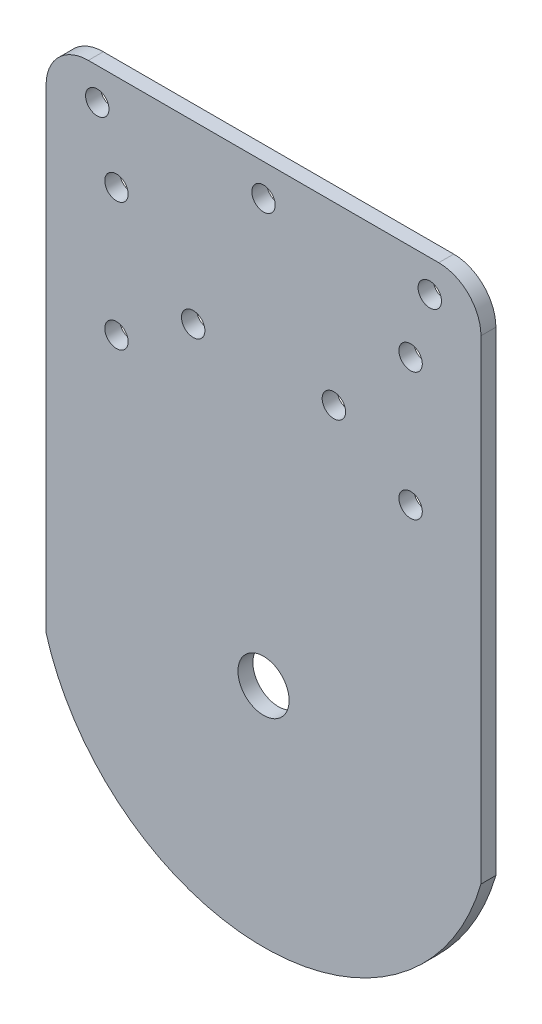
from build123d import *

# Parameters (mm, degrees)
SKETCH1_R             = 4
BOSS_EXTRUDE1_DEPTH   = 2.3368
F_6_CLEARANCE_HOLE1_D = 3.6576
FILLET1_R             = 6.6


with BuildPart() as part:
    # Sketch1 → Boss-Extrude1 (new body)
    with BuildSketch(Plane.XY):
        with BuildLine():
            Line((34, 71), (-34, 71))
            Line((-34, 71), (-34, -9.856977224))
            ThreePointArc((-34, -9.856977224), (0, -35.4), (34, -9.856977224))
            Line((34, -9.856977224), (34, 71))
        make_face()
        Circle(SKETCH1_R, mode=Mode.SUBTRACT)
    extrude(amount=BOSS_EXTRUDE1_DEPTH)

    # 6 Clearance Hole1 (through all)
    with Locations(Plane.XY.offset(2.3368)):
        with Locations((0, 66), (11, 43.5), (23, 36), (23, 56), (26, 66), (-23, 36), (-11, 43.5), (-23, 56), (-26, 66)):
            Hole(F_6_CLEARANCE_HOLE1_D / 2)

    # Fillet1
    fillet1_edges = [part.edges().sort_by_distance(p)[0] for p in [
        (34, 71, 1.1684),
        (-34, 71, 1.1684),
    ]]
    fillet(fillet1_edges, radius=FILLET1_R)


solid = part.part
